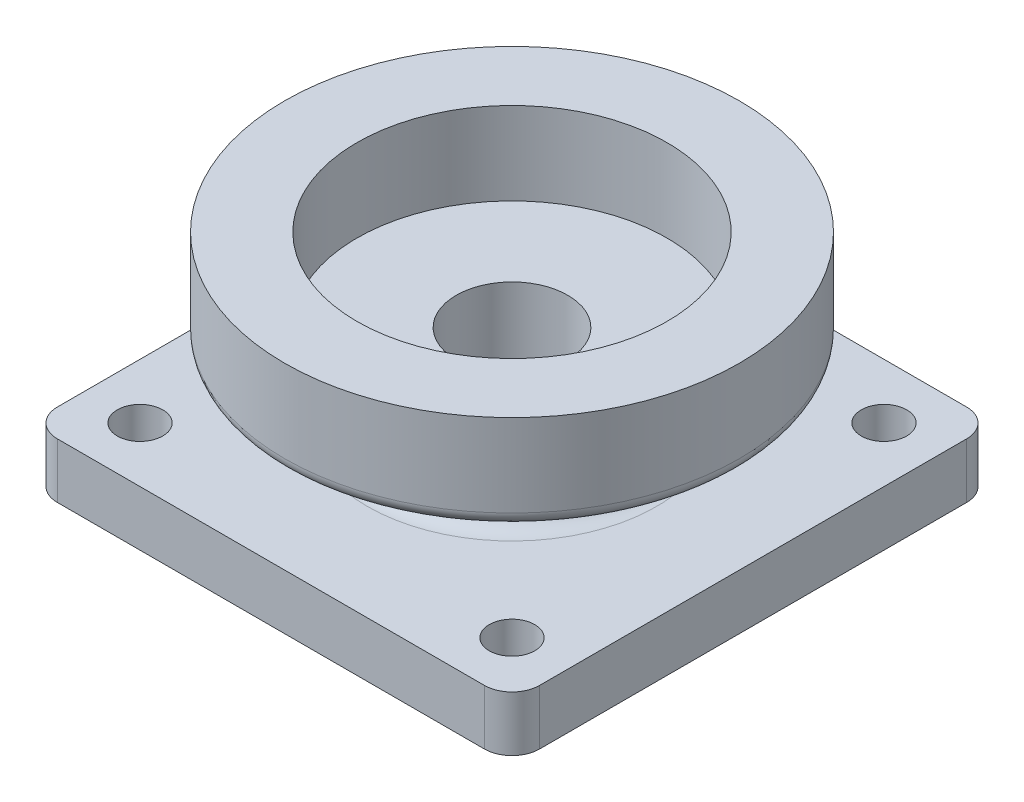
from build123d import *

# Parameters (mm, degrees)
CROQUIS1_W              = 35
CROQUIS1_H              = 35
CROQUIS1_R              = 1.65
CROQUIS1_R_2            = 9
SALIENTE_EXTRUIR1_DEPTH = 4
REDONDEO2_R             = 2
CROQUIS1_8_R            = 9
CROQUIS1_8_R_2          = 4.05
SALIENTE_EXTRUIR2_DEPTH = 9
CROQUIS2_R              = 16.5
CROQUIS2_R_2            = 11.25
SALIENTE_EXTRUIR3_DEPTH = 7
REDONDEO3_R             = 1.5
CROQUIS2_3_R            = 11.25
CROQUIS2_3_R_2          = 9
CROQUIS2_3_R_3          = 4.05
SALIENTE_EXTRUIR4_DEPTH = 1
REDONDEO4_R             = 1.5
REDONDEO5_R             = 1


with BuildPart() as part:
    # Croquis1 → Saliente-Extruir1 (new body)
    with BuildSketch(Plane(origin=(0, 0, 0), x_dir=(1, 0, 0), z_dir=(0, 1, 0))):
        Rectangle(CROQUIS1_W, CROQUIS1_H)
        with Locations((-13.5, -13.5)):
            Circle(CROQUIS1_R, mode=Mode.SUBTRACT)
        with Locations((13.5, -13.5)):
            Circle(CROQUIS1_R, mode=Mode.SUBTRACT)
        with Locations((13.5, 13.5)):
            Circle(CROQUIS1_R, mode=Mode.SUBTRACT)
        with Locations((-13.5, 13.5)):
            Circle(CROQUIS1_R, mode=Mode.SUBTRACT)
        Circle(CROQUIS1_R_2, mode=Mode.SUBTRACT)
    extrude(amount=SALIENTE_EXTRUIR1_DEPTH)

    # Redondeo2
    redondeo2_edges = [part.edges().sort_by_distance(p)[0] for p in [
        (17.5, 2, 17.5),
        (-17.5, 2, 17.5),
        (-17.5, 2, -17.5),
        (17.5, 2, -17.5),
    ]]
    fillet(redondeo2_edges, radius=REDONDEO2_R)

    # Croquis1_8 → Saliente-Extruir2 (add)
    with BuildSketch(Plane(origin=(0, 0, 0), x_dir=(1, 0, 0), z_dir=(0, 1, 0))):
        Circle(CROQUIS1_8_R)
        Circle(CROQUIS1_8_R_2, mode=Mode.SUBTRACT)
    extrude(amount=SALIENTE_EXTRUIR2_DEPTH)

    # Redondeo3
    redondeo3_edges = [part.edges().sort_by_distance(p)[0] for p in [
        (-9, 4, 0),
    ]]
    fillet(redondeo3_edges, radius=REDONDEO3_R)



with BuildPart() as body_2:
    # Croquis2 → Saliente-Extruir3 (new body)
    with BuildSketch(Plane(origin=(0, 9, 0), x_dir=(1, 0, 0), z_dir=(0, 1, 0))):
        Circle(CROQUIS2_R)
        Circle(CROQUIS2_R_2, mode=Mode.SUBTRACT)
    extrude(amount=SALIENTE_EXTRUIR3_DEPTH)


with BuildPart() as part_1:
    add(part.part)

    add(body_2.part)  # Saliente-Extruir4 merges body 2
    # Croquis2_3 → Saliente-Extruir4 (add)
    with BuildSketch(Plane(origin=(0, 9, 0), x_dir=(1, 0, 0), z_dir=(0, 1, 0))):
        Circle(CROQUIS2_3_R)
        Circle(CROQUIS2_3_R_2, mode=Mode.SUBTRACT)
        Circle(CROQUIS2_3_R_2)
        Circle(CROQUIS2_3_R_3, mode=Mode.SUBTRACT)
    extrude(amount=SALIENTE_EXTRUIR4_DEPTH)

    # Redondeo4
    redondeo4_edges = [part_1.edges().sort_by_distance(p)[0] for p in [
        (-9, 9, 0),
    ]]
    fillet(redondeo4_edges, radius=REDONDEO4_R)

    # Redondeo5
    redondeo5_edges = [part_1.edges().sort_by_distance(p)[0] for p in [
        (-16.5, 9, 0),
    ]]
    fillet(redondeo5_edges, radius=REDONDEO5_R)


solid = part_1.part
